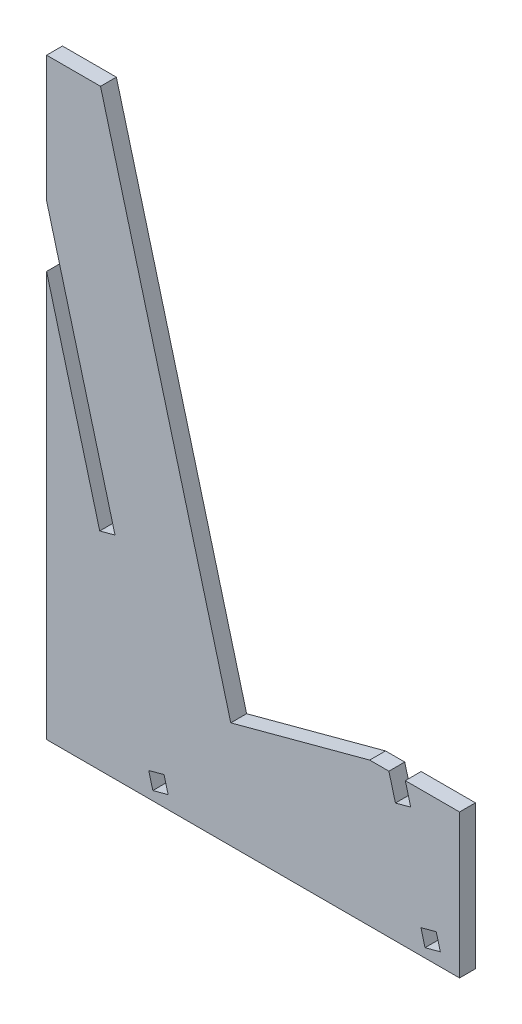
from build123d import *

# Parameters (mm, degrees)
BOSS_EXTRUDE1_DEPTH = 2.8
CUT_EXTRUDE1_DEPTH  = 3.8
CUT_EXTRUDE2_DEPTH  = 3.8


with BuildPart() as part:
    # Sketch1 → Boss-Extrude1 (new body)
    with BuildSketch(Plane.XY):
        Polygon((-38.029024976, 83.602786166), (-38.029024976, -21.094016045), (34.914504121, -21.094016045), (34.914504121, 4.305983955), (19.039504121, 4.305983955), (-5.495011867, -2.268019791), (-28.504024976, 83.602786166), align=None)
    extrude(amount=BOSS_EXTRUDE1_DEPTH)

    # Sketch2 → Cut-Extrude1 (cut, through all)
    with BuildSketch(Plane.XY.offset(2.8)):
        Polygon((-19.264644206, -19.506516045), (-16.560051893, -18.781822719), (-17.284745219, -16.077230405), (-19.989337533, -16.801923732), align=None)
        Polygon((-28.646834591, 15.508295158), (-25.942242278, 16.232988484), (-35.324432663, 51.247799687), (-38.029024976, 61.341475615), (-38.029024976, 50.523106361), align=None)
    extrude(amount=-CUT_EXTRUDE1_DEPTH, mode=Mode.SUBTRACT)

    # Sketch3 → Cut-Extrude2 (cut, through all)
    with BuildSketch(Plane.XY.offset(2.8)):
        Polygon((28.814978037, -19.506516045), (31.51957035, -18.781822719), (30.794877024, -16.077230405), (28.09028471, -16.801923732), align=None)
        Polygon((23.58624935, 0.007365071), (26.290841664, 0.732058397), (25.333211197, 4.305983955), (22.434437892, 4.305983955), (22.628618883, 3.581290628), align=None)
    extrude(amount=-CUT_EXTRUDE2_DEPTH, mode=Mode.SUBTRACT)


solid = part.part
